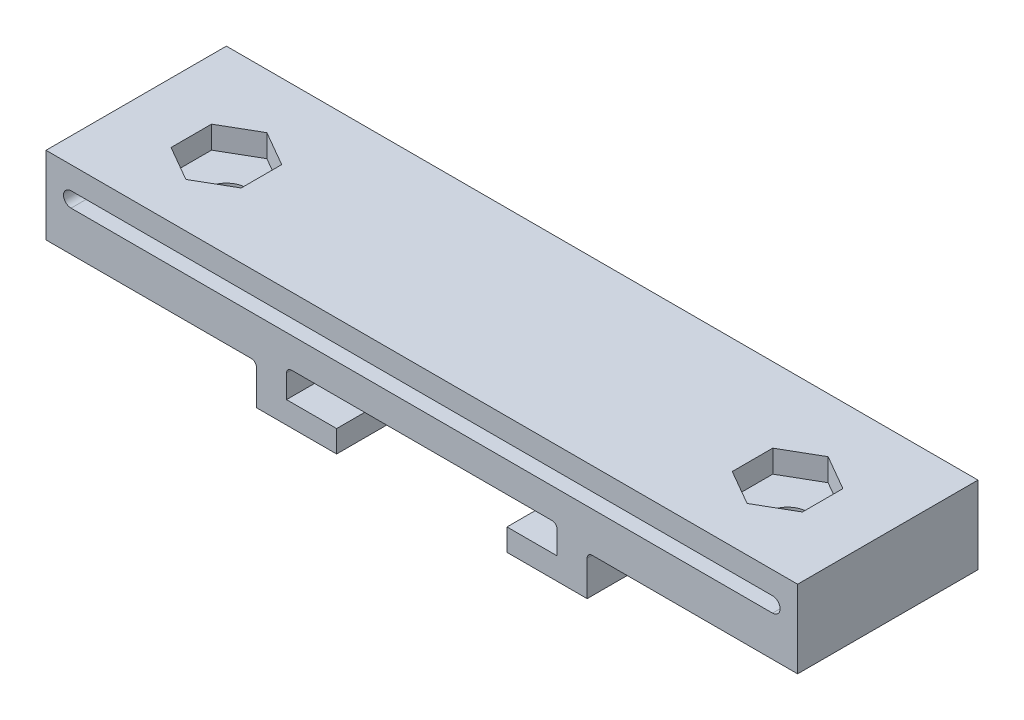
from build123d import *

# Parameters (mm, degrees)
DODANIE_WYCI_GNI_CIE1_DEPTH = 18
WYTNIJ_WYCI_GNI_CIE1_START  = -4
SZKIC4_R                    = 5
WYTNIJ_WYCI_GNI_CIE1_DEPTH  = 2
SZKIC5_R                    = 2
WYTNIJ_WYCI_GNI_CIE2_DEPTH  = 2.653427208
ZAOKR_GLENIE1_R             = 0.5
DODANIE_WYCI_GNI_CIE2_DEPTH = 18
WYTNIJ_WYCI_GNI_CIE3_REACH  = 13.75
SFAZOWANIE1_SIZE            = 1.5


with BuildPart() as part:
    # Szkic1 → Dodanie-wyciągnięcie1 (new body)
    with BuildSketch(Plane.XY):
        Polygon((-13.5, 3.7), (-13.5, 6.5), (13.5, 6.5), (13.5, 3.7), (8.5, 3.7), (8.5, 1.5), (16.5, 1.5), (16.5, 5.5), (35, 5.5), (35, 9.5), (-35, 9.5), (-35, 5.5), (-16.5, 5.5), (-16.5, 1.5), (-8.5, 1.5), (-8.5, 3.7), align=None)
    extrude(amount=DODANIE_WYCI_GNI_CIE1_DEPTH)

    # Szkic4 → Wytnij-wyciągnięcie1 (cut)
    with BuildSketch(Plane(origin=(0, 9.5, 0), x_dir=(1, 0, 0), z_dir=(0, 1, 0)).offset(WYTNIJ_WYCI_GNI_CIE1_START)):
        with Locations((-28, -9.5)):
            Circle(SZKIC4_R)
        with Locations((28, -9.5)):
            Circle(SZKIC4_R)
    extrude(amount=WYTNIJ_WYCI_GNI_CIE1_DEPTH, mode=Mode.SUBTRACT)

    # Szkic5 → Wytnij-wyciągnięcie2 (cut)
    with BuildSketch(Plane(origin=(0, 7.5, 0), x_dir=(-1, 0, 0), z_dir=(0, -1, 0))):
        with Locations((28, -9.5)):
            Circle(SZKIC5_R)
        with Locations((-28, -9.5)):
            Circle(SZKIC5_R)
    extrude(amount=-WYTNIJ_WYCI_GNI_CIE2_DEPTH, mode=Mode.SUBTRACT)

    # Zaokrąglenie1
    zaokr_glenie1_edges = [part.edges().sort_by_distance(p)[0] for p in [
        (-16.5, 5.5, 9),
        (16.5, 5.5, 9),
        (13.5, 6.5, 9),
        (-13.5, 6.5, 9),
    ]]
    fillet(zaokr_glenie1_edges, radius=ZAOKR_GLENIE1_R)

    # Szkic6 → Dodanie-wyciągnięcie2 (add)
    with BuildSketch(Plane.XY.offset(18)):
        with BuildLine():
            Line((35, 11), (-35, 11))
            ThreePointArc((-35, 11), (-35.75, 10.25), (-35, 9.5))
            Line((-35, 9.5), (-35, 5.5))
            Line((-35, 5.5), (-37.5, 5.5))
            Line((-37.5, 5.5), (-37.5, 13.25))
            Line((-37.5, 13.25), (37.5, 13.25))
            Line((37.5, 13.25), (37.5, 5.5))
            Line((37.5, 5.5), (35, 5.5))
            Line((35, 5.5), (35, 9.5))
            ThreePointArc((35, 9.5), (35.75, 10.25), (35, 11))
        make_face()
    extrude(amount=-DODANIE_WYCI_GNI_CIE2_DEPTH)

    # Szkic7 → Wytnij-wyciągnięcie3 (cut, up to next)
    with BuildSketch(Plane(origin=(0, 13.25, 0), x_dir=(1, 0, 0), z_dir=(0, 1, 0)), mode=Mode.PRIVATE) as wytnij_wyci_gni_cie3_sk1:
        Polygon((-31.5, -7.479274058), (-31.5, -11.520725942), (-28, -13.541451884), (-24.5, -11.520725942), (-24.5, -7.479274058), (-28, -5.458548116), align=None)
    wytnij_wyci_gni_cie3_tool1 = extrude(wytnij_wyci_gni_cie3_sk1.sketch, amount=-WYTNIJ_WYCI_GNI_CIE3_REACH, mode=Mode.PRIVATE) & part.part
    add(wytnij_wyci_gni_cie3_tool1.solids().sort_by_distance((-28, 13.25, 9.5))[0], mode=Mode.SUBTRACT)
    # Szkic7 → Wytnij-wyciągnięcie3 (cut, up to next)
    with BuildSketch(Plane(origin=(0, 13.25, 0), x_dir=(1, 0, 0), z_dir=(0, 1, 0)), mode=Mode.PRIVATE) as wytnij_wyci_gni_cie3_sk2:
        Polygon((28, -5.458548116), (24.5, -7.479274058), (24.5, -11.520725942), (28, -13.541451884), (31.5, -11.520725942), (31.5, -7.479274058), align=None)
    wytnij_wyci_gni_cie3_tool2 = extrude(wytnij_wyci_gni_cie3_sk2.sketch, amount=-WYTNIJ_WYCI_GNI_CIE3_REACH, mode=Mode.PRIVATE) & part.part
    add(wytnij_wyci_gni_cie3_tool2.solids().sort_by_distance((28, 13.25, 9.5))[0], mode=Mode.SUBTRACT)

    # Sfazowanie1
    sfazowanie1_edges = [part.edges().sort_by_distance(p)[0] for p in [
        (-8.5, 2.6, 0),
        (8.5, 2.6, 0),
        (11, 3.7, 0),
        (-13.5, 4.85, 0),
        (-11, 3.7, 0),
        (0, 6.5, 0),
        (13.5, 4.85, 0),
        (-13.353553391, 6.353553391, 0),
        (13.353553391, 6.353553391, 0),
    ]]
    chamfer(sfazowanie1_edges, length=SFAZOWANIE1_SIZE)


solid = part.part
